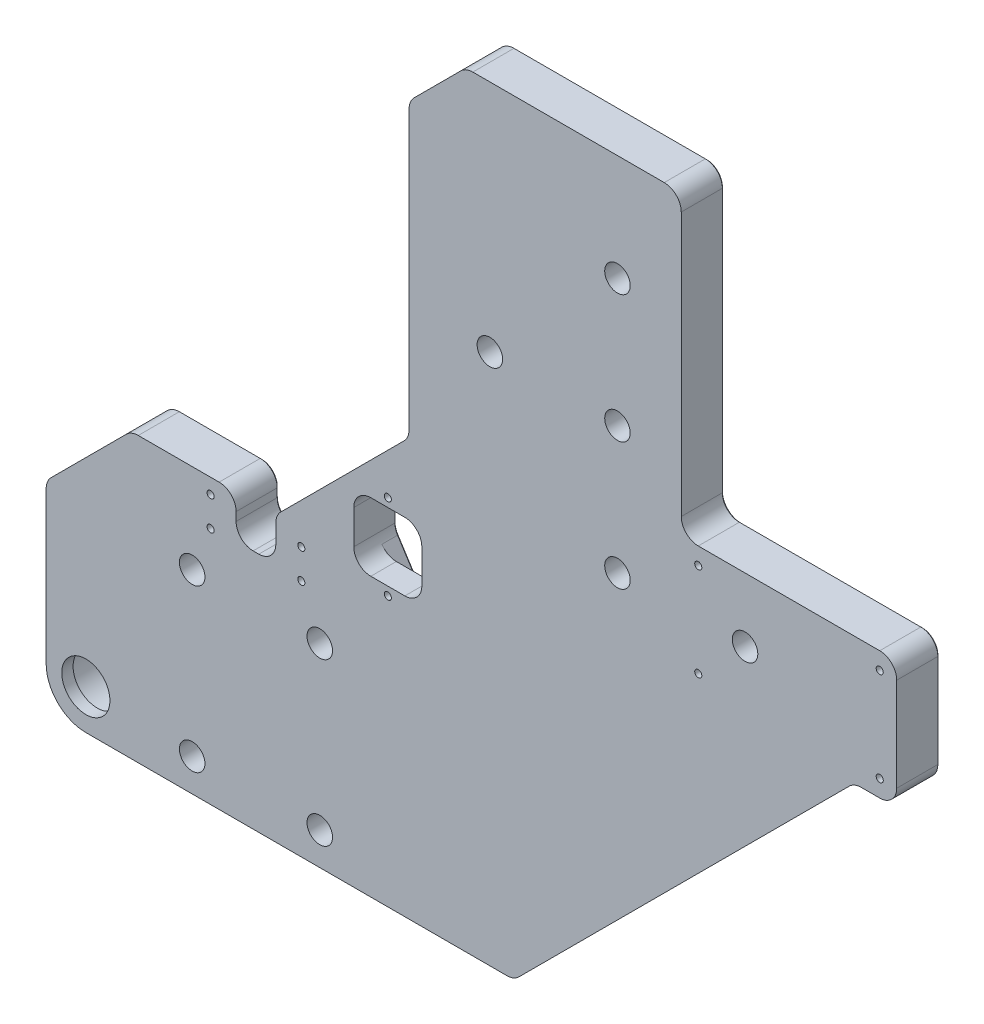
from build123d import *

# Parameters (mm, degrees)
BOSS_EXTRU_1_DEPTH                                 = 15
CHAMBRAGE_POUR_VIS_T_TE_HEXAGONALE_M81_D           = 9
CHAMBRAGE_POUR_VIS_T_TE_HEXAGONALE_M81_CBORE_D     = 15
CHAMBRAGE_POUR_VIS_T_TE_HEXAGONALE_M81_CBORE_DEPTH = 8.6
TAP_DRILL_FOR_M5_TAP1_D                            = 4.2
TAP_DRILL_FOR_M5_TAP1_DEPTH                        = 13
TAP_DRILL_FOR_M5_TAP1_TIP                          = 1.2618073
SKETCH25_W                                         = 14
SKETCH25_H                                         = 15
CUT_EXTRUDE6_DEPTH                                 = 16
CONG_1_R                                           = 6
SKETCH11_R                                         = 8.5
CUT_EXTRUDE1_DEPTH                                 = 16
SKETCH12_R                                         = 11
CUT_EXTRUDE2_DEPTH                                 = 11
SKETCH13_W                                         = 24
SKETCH13_H                                         = 24
CUT_EXTRUDE3_DEPTH                                 = 16
FILLET1_R                                          = 6
CUT_EXTRUDE4_DEPTH                                 = 6
FILLET3_R                                          = 14
TAP_DRILL_FOR_M3_TAP1_D                            = 2.5
CHAMFER1_SIZE                                      = 0.5
TAP_DRILL_FOR_M3_TAP2_D                            = 2.5
TAP_DRILL_FOR_M3_TAP3_D                            = 2.5


with BuildPart() as part:
    # Esquisse1 → Boss.-Extru.1 (new body)
    with BuildSketch(Plane.XY):
        Polygon((-21.072673536, 123.242590707), (54.927326464, 123.242590707), (54.927326464, 18.242590707), (130.927326464, 18.242590707), (130.927326464, -26.757409293), (115.927326464, -26.757409293), (-4.072673536, -146.757409293), (-169.072673536, -146.757409293), (-169.072673536, -76.757409293), (-139.072673536, -46.757409293), (-88.072673536, -46.757409293), (-41.072673536, 0.242590707), (-41.072673536, 103.242590707), align=None)
    extrude(amount=BOSS_EXTRU_1_DEPTH)

    # Chambrage pour vis à tête hexagonale M81 (through all)
    with Locations(Plane(origin=(0, 0, 0), x_dir=(-1, 0, 0), z_dir=(0, 0, -1))):
        with Locations((72.572673536, -78.257409293), (117.572673536, -78.257409293), (72.572673536, -135.257409293), (117.572673536, -135.257409293), (-32.427326464, 85.742590707), (-32.427326464, 40.742590707), (-32.427326464, -4.257409293), (-77.427326464, -4.257409293), (12.572673536, 40.742590707)):
            CounterBoreHole(CHAMBRAGE_POUR_VIS_T_TE_HEXAGONALE_M81_D / 2, CHAMBRAGE_POUR_VIS_T_TE_HEXAGONALE_M81_CBORE_D / 2, CHAMBRAGE_POUR_VIS_T_TE_HEXAGONALE_M81_CBORE_DEPTH)

    # Tap Drill for M5 Tap1
    with Locations(Plane(origin=(0, -146.757409293, 0), x_dir=(-1, 0, 0), z_dir=(0, -1, 0))):
        with Locations((13.072673536, -7.5)):
            Hole(TAP_DRILL_FOR_M5_TAP1_D / 2, depth=TAP_DRILL_FOR_M5_TAP1_DEPTH)
            with Locations((0, 0, -(TAP_DRILL_FOR_M5_TAP1_DEPTH + TAP_DRILL_FOR_M5_TAP1_TIP / 2))):  # 118° drill point
                Cone(0, TAP_DRILL_FOR_M5_TAP1_D / 2, TAP_DRILL_FOR_M5_TAP1_TIP, mode=Mode.SUBTRACT)

    # Sketch25 → Cut-Extrude6 (cut, through all)
    with BuildSketch(Plane(origin=(0, 0, 0), x_dir=(-1, 0, 0), z_dir=(0, 0, -1))):
        with Locations((95.072673536, -54.257409293)):
            Rectangle(SKETCH25_W, SKETCH25_H)
    extrude(amount=-CUT_EXTRUDE6_DEPTH, mode=Mode.SUBTRACT)

    # Congé1
    cong_1_edges = [part.edges().sort_by_distance(p)[0] for p in [
        (-88.072673536, -61.757409293, 7.5),
        (-102.072673536, -46.757409293, 7.5),
        (-102.072673536, -61.757409293, 7.5),
        (54.927326464, 18.242590707, 7.5),
        (130.927326464, 18.242590707, 7.5),
        (130.927326464, -26.757409293, 7.5),
        (115.927326464, -26.757409293, 7.5),
        (-4.072673536, -146.757409293, 7.5),
        (-169.072673536, -76.757409293, 7.5),
        (-139.072673536, -46.757409293, 7.5),
        (-88.072673536, -46.757409293, 7.5),
        (-41.072673536, 0.242590707, 7.5),
        (-41.072673536, 103.242590707, 7.5),
        (-21.072673536, 123.242590707, 7.5),
        (54.927326464, 123.242590707, 7.5),
    ]]
    fillet(cong_1_edges, radius=CONG_1_R)

    # Sketch11 → Cut-Extrude1 (cut, through all)
    with BuildSketch(Plane(origin=(0, 0, 0), x_dir=(-1, 0, 0), z_dir=(0, 0, -1))):
        with Locations((155.072673536, -132.757409293)):
            Circle(SKETCH11_R)
    extrude(amount=-CUT_EXTRUDE1_DEPTH, mode=Mode.SUBTRACT)

    # Sketch12 → Cut-Extrude2 (cut)
    with BuildSketch(Plane(origin=(0, 0, 0), x_dir=(-1, 0, 0), z_dir=(0, 0, -1))):
        with Locations((155.072673536, -132.757409293)):
            Circle(SKETCH12_R)
    extrude(amount=-CUT_EXTRUDE2_DEPTH, mode=Mode.SUBTRACT)

    # Sketch13 → Cut-Extrude3 (cut, through all)
    with BuildSketch(Plane(origin=(0, 0, 0), x_dir=(-1, 0, 0), z_dir=(0, 0, -1))):
        with Locations((48.572673536, -36.757409293)):
            Rectangle(SKETCH13_W, SKETCH13_H)
    extrude(amount=-CUT_EXTRUDE3_DEPTH, mode=Mode.SUBTRACT)

    # Fillet1
    fillet1_edges = [part.edges().sort_by_distance(p)[0] for p in [
        (-36.572673536, -48.757409293, 7.5),
        (-36.572673536, -24.757409293, 7.5),
        (-60.572673536, -24.757409293, 7.5),
        (-60.572673536, -48.757409293, 7.5),
    ]]
    fillet(fillet1_edges, radius=FILLET1_R)

    # Sketch14 → Cut-Extrude4 (cut)
    with BuildSketch(Plane(origin=(0, 0, 0), x_dir=(-1, 0, 0), z_dir=(0, 0, -1))):
        with BuildLine():
            Line((53.794093198, -18.414240629), (59.625660306, -27.52208478))
            ThreePointArc((59.625660306, -27.52208478), (60.33105528, -29.071870895), (60.572673536, -30.757409293))
            Line((60.572673536, -30.757409293), (60.572673536, -42.757409293))
            ThreePointArc((60.572673536, -42.757409293), (60.33105528, -44.442947691), (59.625660306, -45.992733806))
            Line((59.625660306, -45.992733806), (53.794093198, -55.100577956))
            ThreePointArc((53.794093198, -55.100577956), (48.572673536, -57.957409293), (43.351253874, -55.100577956))
            Line((43.351253874, -55.100577956), (37.519686767, -45.992733806))
            ThreePointArc((37.519686767, -45.992733806), (36.814291792, -44.442947691), (36.572673536, -42.757409293))
            Line((36.572673536, -42.757409293), (36.572673536, -30.757409293))
            ThreePointArc((36.572673536, -30.757409293), (36.814291792, -29.071870895), (37.519686767, -27.52208478))
            Line((37.519686767, -27.52208478), (43.351253874, -18.414240629))
            ThreePointArc((43.351253874, -18.414240629), (48.572673536, -15.557409293), (53.794093198, -18.414240629))
        make_face()
    extrude(amount=-CUT_EXTRUDE4_DEPTH, mode=Mode.SUBTRACT)

    # Fillet3
    fillet3_edges = [part.edges().sort_by_distance(p)[0] for p in [
        (-169.072673536, -146.757409293, 7.5),
    ]]
    fillet(fillet3_edges, radius=FILLET3_R)

    # Tap Drill for M3 Tap1 (through all)
    with Locations(Plane(origin=(0, 0, 6), x_dir=(-1, 0, 0), z_dir=(0, 0, -1))):
        with Locations((48.572673536, -21.757409293), (48.572673536, -51.757409293)):
            Hole(TAP_DRILL_FOR_M3_TAP1_D / 2)

    # Chamfer1
    chamfer1_edges = [part.edges().sort_by_distance(p)[0] for p in [
        (-102.072673536, -54.257409293, 0),
        (-95.072673536, -61.757409293, 0),
        (-88.072673536, -52.50004998, 0),
        (-122.330032849, -46.757409293, 0),
        (-64.572673536, -23.257409293, 0),
        (-41.072673536, 51.742590707, 0),
        (-31.072673536, 113.242590707, 0),
        (15.169967151, 123.242590707, 0),
        (54.927326464, 70.742590707, 0),
        (92.927326464, 18.242590707, 0),
        (130.927326464, -4.257409293, 0),
        (121.669967151, -26.757409293, 0),
        (55.927326464, -86.757409293, 0),
        (-169.072673536, -106.00004998, 0),
        (-154.072673536, -61.757409293, 0),
        (53.169967151, 121.485231394, 0),
        (-20.883492756, 122.785867902, 0),
        (-138.883492756, -47.214132098, 0),
        (-168.615950731, -76.946590073, 0),
        (-40.615950731, 103.053409927, 0),
        (129.169967151, 16.485231394, 0),
        (129.169967151, -25.00004998, 0),
        (-4.261854316, -146.300686488, 0),
        (-87.615950731, -46.946590073, 0),
        (-103.830032849, -48.514768606, 0),
        (-100.315314223, -60.00004998, 0),
        (-89.830032849, -60.00004998, 0),
        (116.116507244, -27.214132098, 0),
        (-41.529396341, 0.431771487, 0),
        (56.684685777, 19.99995002, 0),
        (-144.072673536, -132.757409293, 0),
        (-60.572673536, -36.757409293, 0),
        (-36.572673536, -36.757409293, 0),
        (-60.33105528, -44.442947691, 0),
        (-36.814291792, -29.071870895, 0),
        (-60.33105528, -29.071870895, 0),
        (-36.814291792, -44.442947691, 0),
        (-56.709876752, -50.546655881, 0),
        (-40.43547032, -50.546655881, 0),
        (-48.572673536, -57.957409293, 0),
        (-40.43547032, -22.968162704, 0),
        (-56.709876752, -22.968162704, 0),
        (-48.572673536, -15.557409293, 0),
        (-80.815314223, -146.757409293, 0),
        (-164.972168473, -142.656904229, 0),
        (-5.072673536, 40.742590707, 0),
        (84.927326464, -4.257409293, 0),
        (39.927326464, -4.257409293, 0),
        (39.927326464, 40.742590707, 0),
        (39.927326464, 85.742590707, 0),
        (-110.072673536, -135.257409293, 0),
        (-65.072673536, -135.257409293, 0),
        (-110.072673536, -78.257409293, 0),
        (-65.072673536, -78.257409293, 0),
    ]]
    chamfer(chamfer1_edges, length=CHAMFER1_SIZE)

    # Tap Drill for M3 Tap2 (through all)
    with Locations(Plane(origin=(0, 0, 0), x_dir=(-1, 0, 0), z_dir=(0, 0, -1))):
        with Locations((-124.927326464, 12.242590707), (-124.927326464, -20.757409293), (-60.927326464, 12.242590707), (-60.927326464, -20.757409293)):
            Hole(TAP_DRILL_FOR_M3_TAP2_D / 2)

    # Tap Drill for M3 Tap3 (through all)
    with Locations(Plane.XY.offset(15)):
        with Locations((-111.072673536, -52.057409293), (-111.072673536, -62.457409293), (-79.072673536, -62.457409293), (-79.072673536, -52.057409293)):
            Hole(TAP_DRILL_FOR_M3_TAP3_D / 2)


solid = part.part
